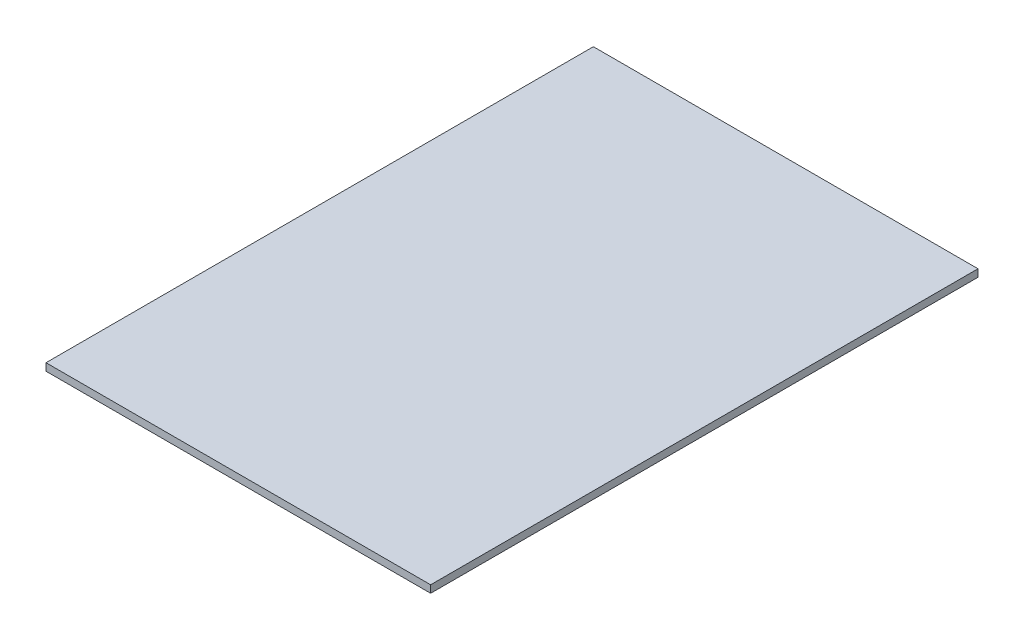
from build123d import *

# Parameters (mm, degrees)
BOSS_EXTRUDE1_DEPTH      = 1.5875
BOSS_EXTRUDE1_DEPTH_BACK = 1.5875
SKETCH1_W                = 165.1
SKETCH1_H                = 234.95


with BuildPart() as part:
    # Sketch1 → Boss-Extrude1 (new, two sides: drawn at the far end of the back side and taken through both)
    with BuildSketch(Plane(origin=(0, 0, 0), x_dir=(1, 0, 0), z_dir=(0, 1, 0)).offset(-BOSS_EXTRUDE1_DEPTH_BACK)):
        Rectangle(SKETCH1_W, SKETCH1_H)
    extrude(amount=BOSS_EXTRUDE1_DEPTH + BOSS_EXTRUDE1_DEPTH_BACK)


solid = part.part
